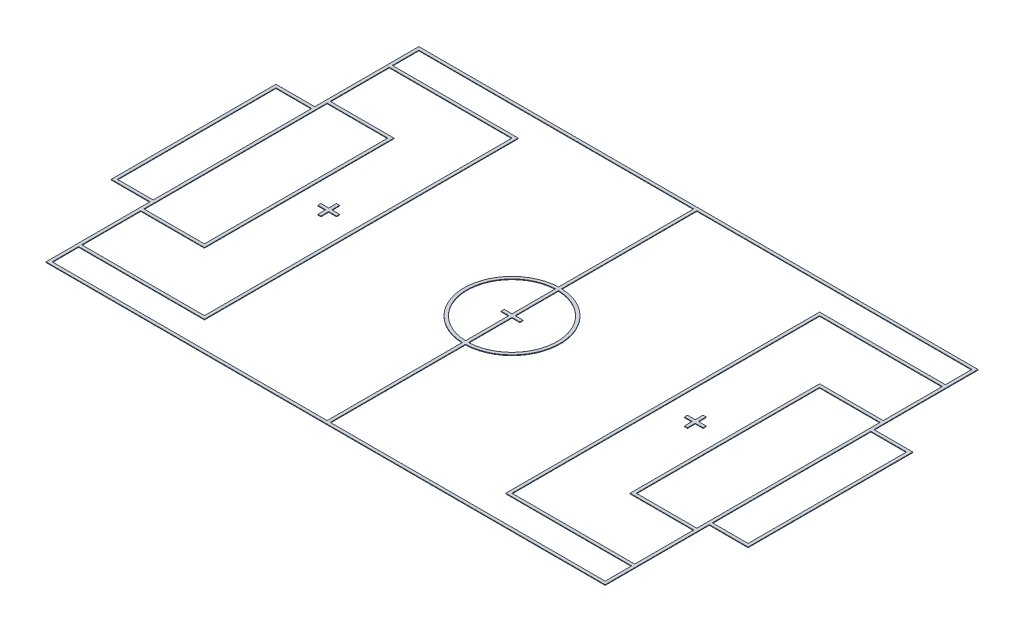
from build123d import *

# Parameters (mm, degrees)
SKETCH1_W             = 975
SKETCH1_H             = 2950
SKETCH1_W_2           = 575
SKETCH1_H_2           = 2550
BOSS_EXTRUDE2_DEPTH   = 10
BOSS_EXTRUDE2_2_DEPTH = 10
BOSS_EXTRUDE2_3_DEPTH = 10


with BuildPart() as part:
    # Sketch1 → Boss-Extrude2 (new body)
    with BuildSketch(Plane(origin=(0, 0, 0), x_dir=(1, 0, 0), z_dir=(0, 1, 0))):
        Polygon((-4500, 3000), (4500, 3000), (4500, 1325), (5125, 1325), (5125, -1325), (4500, -1325), (4500, -3000), (-4500, -3000), (-4500, -1325), (-5125, -1325), (-5125, 1325), (-4500, 1325), align=None)
        with BuildLine():
            Line((-4450, 2950), (-4450, 2525))
            Line((-4450, 2525), (-2425, 2525))
            Line((-2425, 2525), (-2425, -2525))
            Line((-2425, -2525), (-4450, -2525))
            Line((-4450, -2525), (-4450, -2950))
            Line((-4450, -2950), (-25, -2950))
            Line((-25, -2950), (-25, -773.682215065))
            ThreePointArc((-25, -773.682215065), (-774.086022292, 0), (-25, 773.682215065))
            Line((-25, 773.682215065), (-25, 2950))
            Line((-25, 2950), (-4450, 2950))
        make_face(mode=Mode.SUBTRACT)
        with BuildLine():
            Line((4450, 2950), (4450, 2525))
            Line((4450, 2525), (2425, 2525))
            Line((2425, 2525), (2425, -2525))
            Line((2425, -2525), (4450, -2525))
            Line((4450, -2525), (4450, -2950))
            Line((4450, -2950), (25, -2950))
            Line((25, -2950), (25, -773.682215065))
            ThreePointArc((25, -773.682215065), (774.086022292, 0), (25, 773.682215065))
            Line((25, 773.682215065), (25, 2950))
            Line((25, 2950), (4450, 2950))
        make_face(mode=Mode.SUBTRACT)
        with BuildLine():
            Line((-25, 723.591162127), (-25, 25))
            Line((-25, 25), (-150, 25))
            Line((-150, 25), (-150, -25))
            Line((-150, -25), (-25, -25))
            Line((-25, -25), (-25, -723.591162127))
            ThreePointArc((-25, -723.591162127), (-724.022907033, 0), (-25, 723.591162127))
        make_face(mode=Mode.SUBTRACT)
        with BuildLine():
            Line((25, 723.591162127), (25, 25))
            Line((25, 25), (150, 25))
            Line((150, 25), (150, -25))
            Line((150, -25), (25, -25))
            Line((25, -25), (25, -723.591162127))
            ThreePointArc((25, -723.591162127), (724.022907033, 0), (25, 723.591162127))
        make_face(mode=Mode.SUBTRACT)
        with Locations((-3962.5, 0)):
            Rectangle(SKETCH1_W, SKETCH1_H, mode=Mode.SUBTRACT)
        Polygon((-4450, 2475), (-2475, 2475), (-2475, -2475), (-4450, -2475), (-4450, -1525), (-3425, -1525), (-3425, 1525), (-4450, 1525), align=None, mode=Mode.SUBTRACT)
        with Locations((-4787.5, 0)):
            Rectangle(SKETCH1_W_2, SKETCH1_H_2, mode=Mode.SUBTRACT)
        with Locations((4787.5, 0)):
            Rectangle(SKETCH1_W_2, SKETCH1_H_2, mode=Mode.SUBTRACT)
        Polygon((3425, -1525), (4450, -1525), (4450, -2475), (2475, -2475), (2475, 2475), (4450, 2475), (4450, 1525), (3425, 1525), align=None, mode=Mode.SUBTRACT)
        with Locations((3962.5, 0)):
            Rectangle(SKETCH1_W, SKETCH1_H, mode=Mode.SUBTRACT)
    extrude(amount=BOSS_EXTRUDE2_DEPTH)


with BuildPart() as body_2:
    # Sketch1 → Boss-Extrude2 2 (new body)
    with BuildSketch(Plane(origin=(0, 0, 0), x_dir=(1, 0, 0), z_dir=(0, 1, 0))):
        Polygon((-2975, 150), (-2975, 25), (-3100, 25), (-3100, -25), (-2975, -25), (-2975, -150), (-2925, -150), (-2925, -25), (-2800, -25), (-2800, 25), (-2925, 25), (-2925, 150), align=None)
    extrude(amount=BOSS_EXTRUDE2_2_DEPTH)


with BuildPart() as body_3:
    # Sketch1 → Boss-Extrude2 3 (new body)
    with BuildSketch(Plane(origin=(0, 0, 0), x_dir=(1, 0, 0), z_dir=(0, 1, 0))):
        Polygon((2925, -25), (2800, -25), (2800, 25), (2925, 25), (2925, 150), (2975, 150), (2975, 25), (3100, 25), (3100, -25), (2975, -25), (2975, -150), (2925, -150), align=None)
    extrude(amount=BOSS_EXTRUDE2_3_DEPTH)


solid = Compound([part.part, body_2.part, body_3.part])
